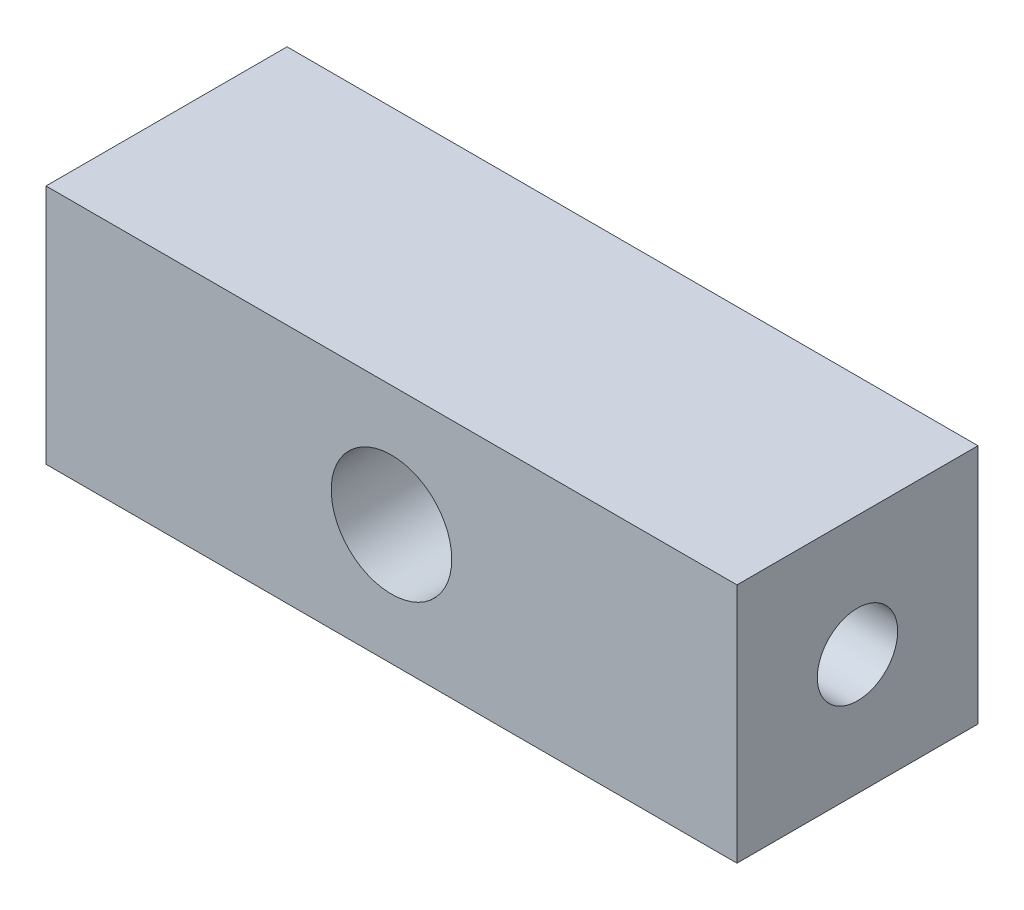
from build123d import *

# Parameters (mm, degrees)
CROQUIS1_W              = 86
CROQUIS1_H              = 30
CROQUIS1_R              = 7.5
SALIENTE_EXTRUIR1_DEPTH = 15
CROQUIS2_R              = 5
CORTAR_EXTRUIR1_DEPTH   = 87


with BuildPart() as part:
    # Croquis1 → Saliente-Extruir1 (new body, symmetric)
    with BuildSketch(Plane.XY):
        Rectangle(CROQUIS1_W, CROQUIS1_H)
        Circle(CROQUIS1_R, mode=Mode.SUBTRACT)
    extrude(amount=SALIENTE_EXTRUIR1_DEPTH, both=True)

    # Croquis2 → Cortar-Extruir1 (cut, through all)
    with BuildSketch(Plane(origin=(43, 0, 0), x_dir=(0, 0, -1), z_dir=(1, 0, 0))):
        Circle(CROQUIS2_R)
    extrude(amount=-CORTAR_EXTRUIR1_DEPTH, mode=Mode.SUBTRACT)


solid = part.part
